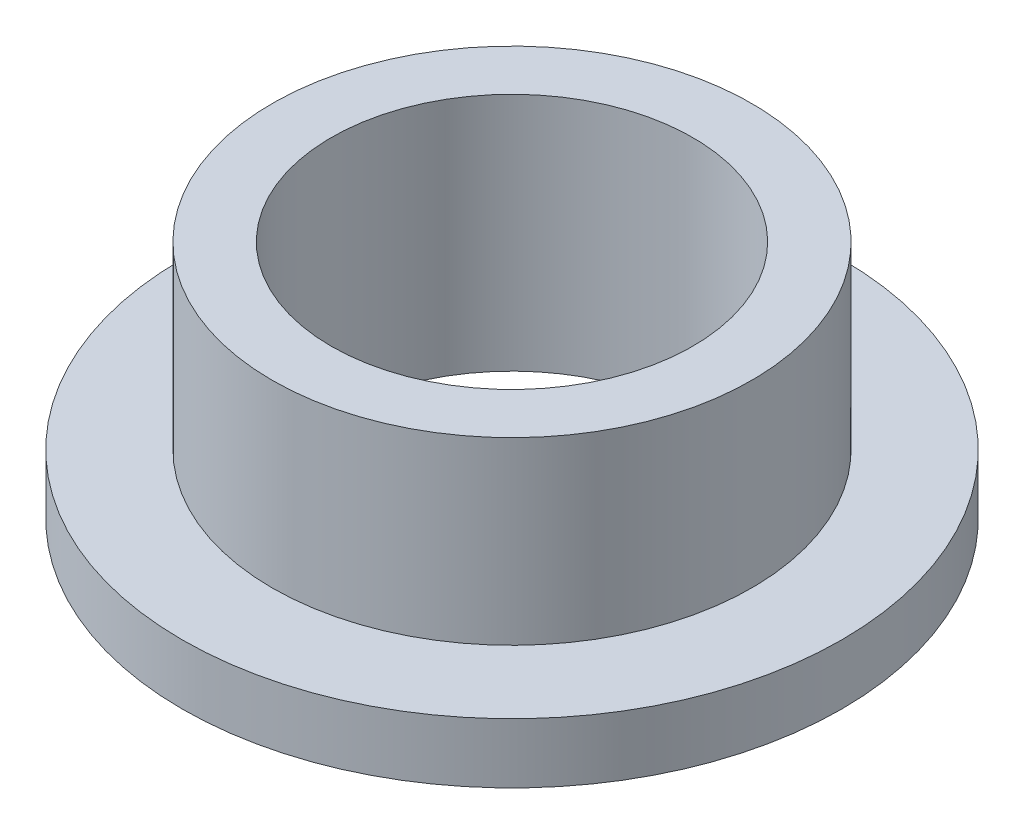
from build123d import *

# Parameters (mm, degrees)
SKETCH2_R           = 6.35
SKETCH2_R_2         = 4.7879
BOSS_EXTRUDE1_DEPTH = 6.35
SKETCH3_R           = 8.73125
SKETCH3_R_2         = 6.35
BOSS_EXTRUDE2_DEPTH = 1.5875


with BuildPart() as part:
    # Sketch2 → Boss-Extrude1 (new body)
    with BuildSketch(Plane(origin=(0, 0, 0), x_dir=(1, 0, 0), z_dir=(0, 1, 0))):
        Circle(SKETCH2_R)
        Circle(SKETCH2_R_2, mode=Mode.SUBTRACT)
    extrude(amount=BOSS_EXTRUDE1_DEPTH)

    # Sketch3 → Boss-Extrude2 (add)
    with BuildSketch(Plane(origin=(0, 0, 0), x_dir=(1, 0, 0), z_dir=(0, 1, 0))):
        Circle(SKETCH3_R)
        Circle(SKETCH3_R_2, mode=Mode.SUBTRACT)
    extrude(amount=BOSS_EXTRUDE2_DEPTH)


solid = part.part
